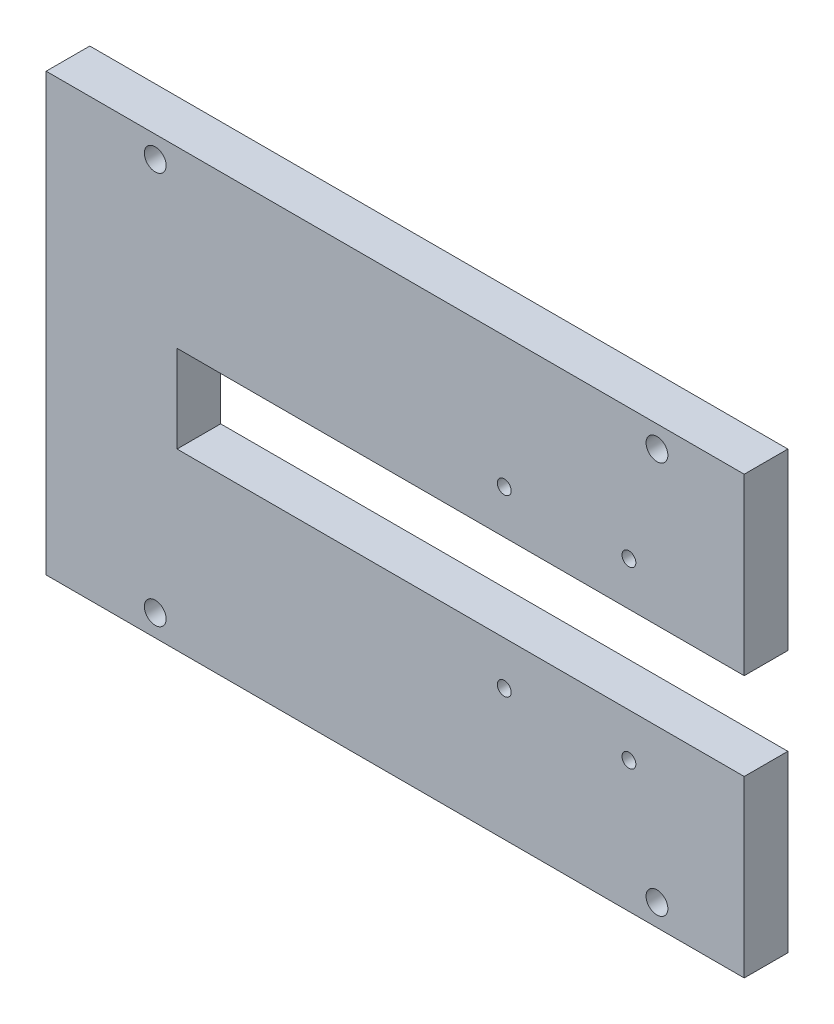
from build123d import *

# Parameters (mm, degrees)
SKETCH1_R           = 1.5875
SKETCH1_R_2         = 2.5
BOSS_EXTRUDE1_DEPTH = 10


with BuildPart() as part:
    # Sketch1 → Boss-Extrude1 (new body)
    with BuildSketch(Plane.XY):
        Polygon((-53.537623716, 64.885018665), (106.462376284, 64.885018665), (106.462376284, 24.885018665), (-23.537623716, 24.885018665), (-23.537623716, 4.885018665), (106.462376284, 4.885018665), (106.462376284, -35.114981335), (-53.537623716, -35.114981335), align=None)
        with Locations((51.462376284, 34.885018665)):
            Circle(SKETCH1_R, mode=Mode.SUBTRACT)
        with Locations((80.037376284, 34.885018665)):
            Circle(SKETCH1_R, mode=Mode.SUBTRACT)
        with Locations((51.462376284, -5.114981335)):
            Circle(SKETCH1_R, mode=Mode.SUBTRACT)
        with Locations((80.037376284, -5.114981335)):
            Circle(SKETCH1_R, mode=Mode.SUBTRACT)
        with Locations((-28.537623716, 59.885018665)):
            Circle(SKETCH1_R_2, mode=Mode.SUBTRACT)
        with Locations((86.462376284, 59.885018665)):
            Circle(SKETCH1_R_2, mode=Mode.SUBTRACT)
        with Locations((-28.537623716, -30.114981335)):
            Circle(SKETCH1_R_2, mode=Mode.SUBTRACT)
        with Locations((86.462376284, -30.114981335)):
            Circle(SKETCH1_R_2, mode=Mode.SUBTRACT)
    extrude(amount=BOSS_EXTRUDE1_DEPTH)


solid = part.part
